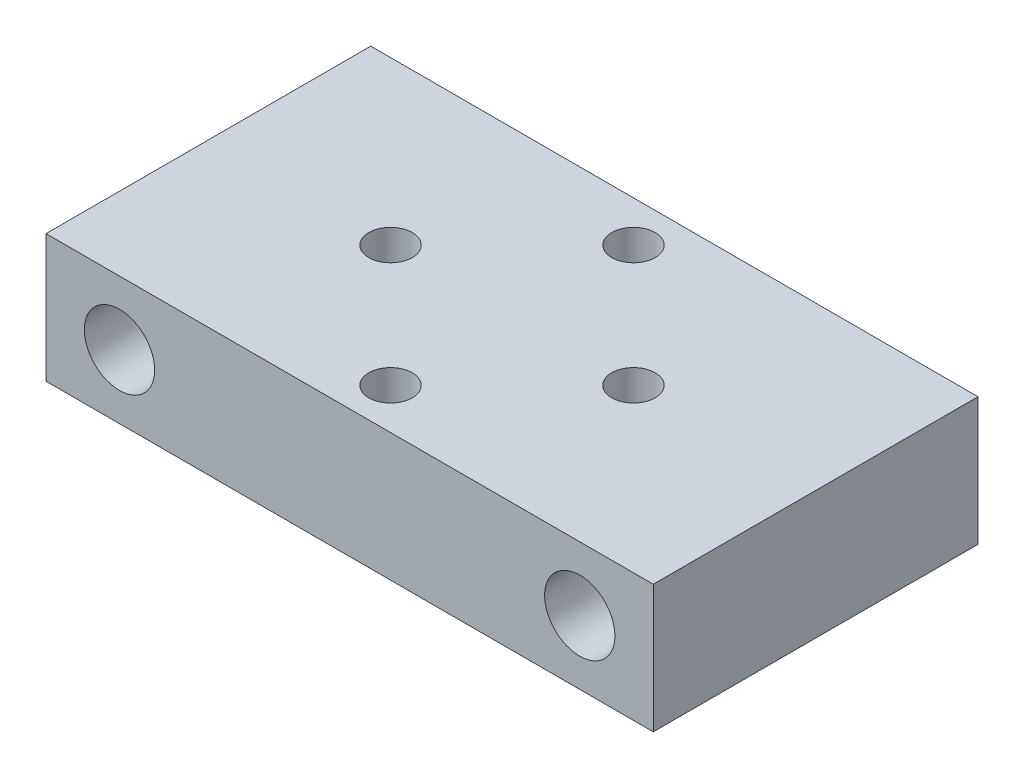
from build123d import *

# Parameters (mm, degrees)
BOSS_EXTRUDE1_DEPTH                             = 5
CSK_FOR_M3_FLAT_HEAD_MACHINE_SCREW1_D           = 3.4
CSK_FOR_M3_FLAT_HEAD_MACHINE_SCREW1_CSINK_D     = 6.3
CSK_FOR_M3_FLAT_HEAD_MACHINE_SCREW1_CSINK_ANGLE = 90
F_5_5_5_5_DIAMETER_HOLE1_AT_2_COUNT             = 2
F_5_5_5_5_DIAMETER_HOLE1_AT_2_PITCH             = 36


with BuildPart() as part:
    # Sketch1 → Boss-Extrude1 (new body, symmetric)
    with BuildSketch(Plane(origin=(0, 0, 0), x_dir=(1, 0, 0), z_dir=(0, 1, 0))):
        Polygon((-23.75, 12.7), (-15.25, 12.7), (15.25, 12.7), (23.75, 12.7), (23.75, -12.7), (15.25, -12.7), (-15.25, -12.7), (-23.75, -12.7), align=None)
    extrude(amount=BOSS_EXTRUDE1_DEPTH, both=True)

    # CSK for M3 Flat Head Machine Screw1 (through all)
    with Locations(Plane(origin=(0, -5, 0), x_dir=(-1, 0, 0), z_dir=(0, -1, 0))):
        with Locations((-9.5, 0), (0, 9.5), (9.5, 0), (0, -9.5)):
            CounterSinkHole(CSK_FOR_M3_FLAT_HEAD_MACHINE_SCREW1_D / 2, CSK_FOR_M3_FLAT_HEAD_MACHINE_SCREW1_CSINK_D / 2, counter_sink_angle=CSK_FOR_M3_FLAT_HEAD_MACHINE_SCREW1_CSINK_ANGLE)

    # Sketch10 → Ø5.5 (5.5) Diameter Hole1 (revolve, cut)
    with BuildSketch(Plane(origin=(-18, 0, 12.7), x_dir=(0, -1, 0), z_dir=(1, 0, 0))):
        Polygon((0, 0), (0, 11.652366702), (2.75, 10), (2.75, 0), align=None)
    f_5_5_5_5_diameter_hole1 = revolve(axis=Axis((-18, 0, 19.05), (0, 0, -1)), mode=Mode.SUBTRACT)

    # Ø5.5 (5.5) Diameter Hole1 at 2: Ø5.5 (5.5) Diameter Hole1 ×2
    with Locations(*[(i * F_5_5_5_5_DIAMETER_HOLE1_AT_2_PITCH, 0, 0) for i in range(1, F_5_5_5_5_DIAMETER_HOLE1_AT_2_COUNT)]):
        add(f_5_5_5_5_diameter_hole1, mode=Mode.SUBTRACT)

    # Mirror1: Ø5.5 (5.5) Diameter Hole1 across plane
    add(f_5_5_5_5_diameter_hole1.mirror(Plane.XY), mode=Mode.SUBTRACT)

    # Mirror1 copy 1 sketch → Mirror1 copy 1 (revolve, cut)
    with BuildSketch(Plane(origin=(18, 0, -12.7), x_dir=(0, -1, 0), z_dir=(1, 0, 0))):
        Polygon((0, 0), (0, -11.652366702), (2.75, -10), (2.75, 0), align=None)
    revolve(axis=Axis((18, 0, -19.05), (0, 0, -1)), mode=Mode.SUBTRACT)


solid = part.part
